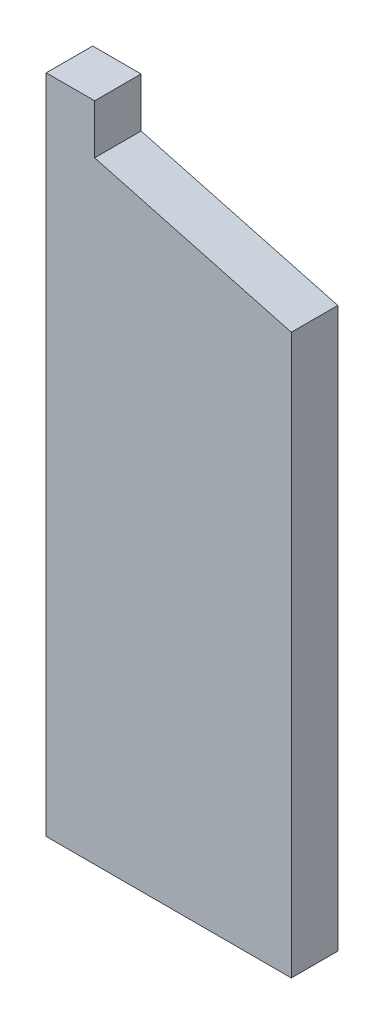
from build123d import *

# Parameters (mm, degrees)
EXTRUDE_1_DEPTH          = 9.4
CUT_EXTRUDE_1_DEPTH      = 1
CUT_EXTRUDE_1_DEPTH_BACK = 10.4


with BuildPart() as part:
    # 草图1 → 凸台-拉伸1 (new body)
    with BuildSketch(Plane.XY):
        Polygon((9.8, 0), (0, 0), (0, -133.83), (49.6, -133.83), (49.6, 0), (39.8, 0), (39.8, -10), (9.8, -10), align=None)
    extrude(amount=EXTRUDE_1_DEPTH)

    # 草图2 → 切除-拉伸1 (cut, two sides)
    with BuildSketch(Plane.XY.offset(9.4)) as cut_extrude_1_sk:
        Polygon((39.8, -10), (9.8, -10), (49.6, -20.664377859), (49.6, 0), (39.8, 0), align=None)
    extrude(amount=CUT_EXTRUDE_1_DEPTH, mode=Mode.SUBTRACT)
    extrude(cut_extrude_1_sk.sketch, amount=-CUT_EXTRUDE_1_DEPTH_BACK, mode=Mode.SUBTRACT)


solid = part.part
